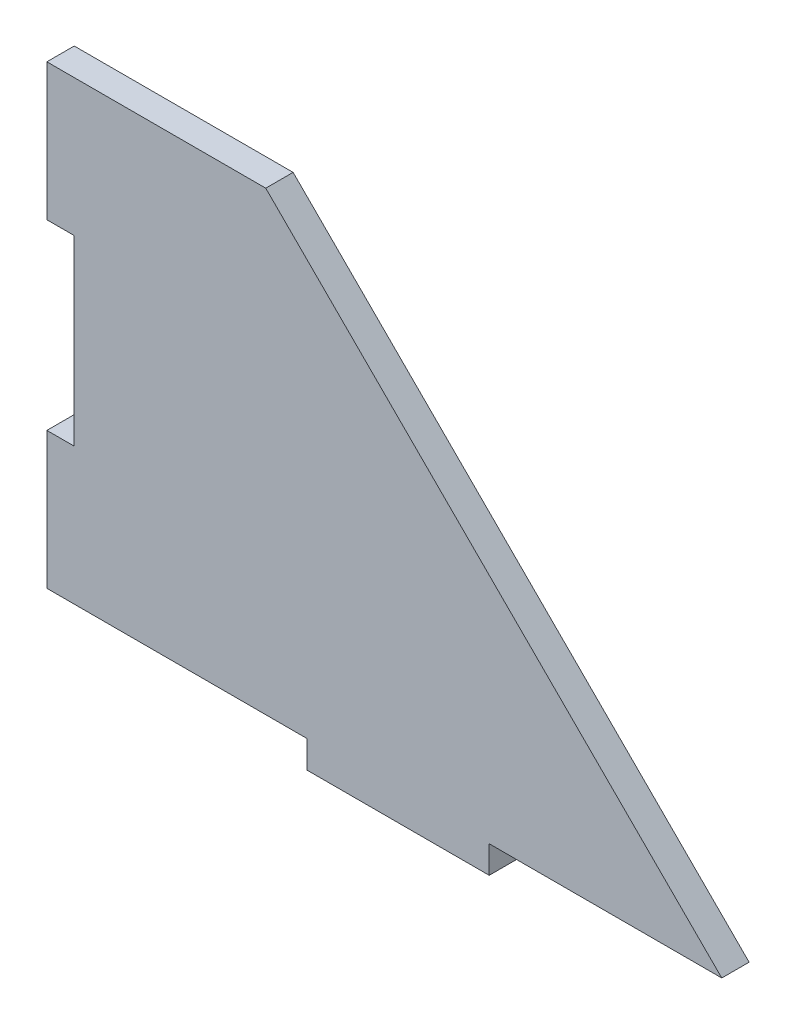
from build123d import *

# Parameters (mm, degrees)
SALIENTE_EXTRUIR1_DEPTH = 3
CROQUIS4_W              = 20
CROQUIS4_H              = 3
SALIENTE_EXTRUIR3_DEPTH = 3
CROQUIS5_W              = 3
CROQUIS5_H              = 20
CORTAR_EXTRUIR1_DEPTH   = 3


with BuildPart() as part:
    # Croquis1 → Saliente-Extruir1 (new body)
    with BuildSketch(Plane.XY):
        Polygon((35.5, -25), (-14.5, 25), (-38.5, 25), (-38.5, -25), align=None)
    extrude(amount=SALIENTE_EXTRUIR1_DEPTH)

    # Croquis4 → Saliente-Extruir3 (add)
    with BuildSketch(Plane.XY.offset(3)):
        with Locations((0, -26.5)):
            Rectangle(CROQUIS4_W, CROQUIS4_H)
    extrude(amount=-SALIENTE_EXTRUIR3_DEPTH)

    # Croquis5 → Cortar-Extruir1 (cut)
    with BuildSketch(Plane.XY.offset(3)):
        with Locations((-37, 0)):
            Rectangle(CROQUIS5_W, CROQUIS5_H)
    extrude(amount=-CORTAR_EXTRUIR1_DEPTH, mode=Mode.SUBTRACT)


solid = part.part
